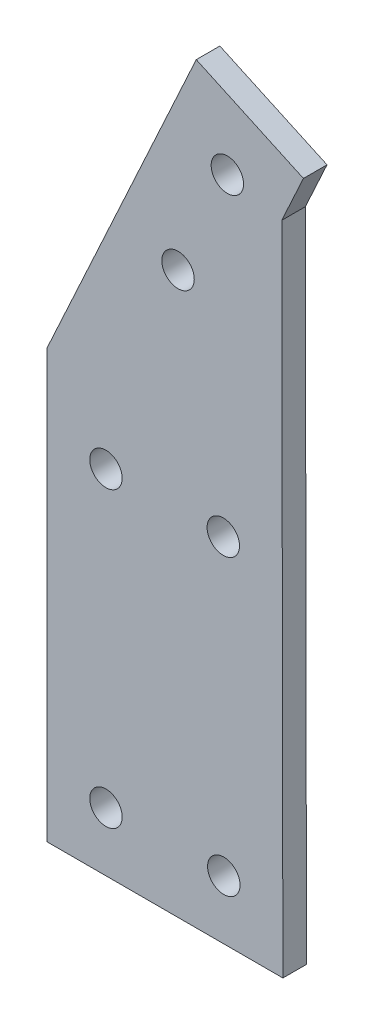
from build123d import *

# Parameters (mm, degrees)
BOSS_EXTRUDE1_DEPTH = 4
SKETCH2_R           = 2.75
CUT_EXTRUDE1_DEPTH  = 4
SKETCH3_R           = 2.75
CUT_EXTRUDE2_DEPTH  = 4


with BuildPart() as part:
    # Sketch1 → Boss-Extrude1 (new body)
    with BuildSketch(Plane.XY):
        Polygon((0, 0), (18.168649127, -8.360633284), (14.494150799, -16.345754575), (14.688182734, -127.505585232), (-25.311817266, -127.505585232), (-25.311817266, -55.005585232), align=None)
    extrude(amount=BOSS_EXTRUDE1_DEPTH)

    # Sketch2 → Cut-Extrude1 (cut)
    with BuildSketch(Plane.XY.offset(4)):
        with Locations((-15.311817266, -117.505585232)):
            Circle(SKETCH2_R)
        with Locations((4.670712279, -117.505585232)):
            Circle(SKETCH2_R)
        with Locations((-15.311817266, -67.755585232)):
            Circle(SKETCH2_R)
        with Locations((4.583872557, -67.755585232)):
            Circle(SKETCH2_R)
    extrude(amount=-CUT_EXTRUDE1_DEPTH, mode=Mode.SUBTRACT)

    # Sketch3 → Cut-Extrude2 (cut)
    with BuildSketch(Plane.XY.offset(4)):
        with Locations((5.271808516, -14.259489296)):
            Circle(SKETCH3_R)
        with Locations((-3.088824768, -32.428138423)):
            Circle(SKETCH3_R)
    extrude(amount=-CUT_EXTRUDE2_DEPTH, mode=Mode.SUBTRACT)


solid = part.part
